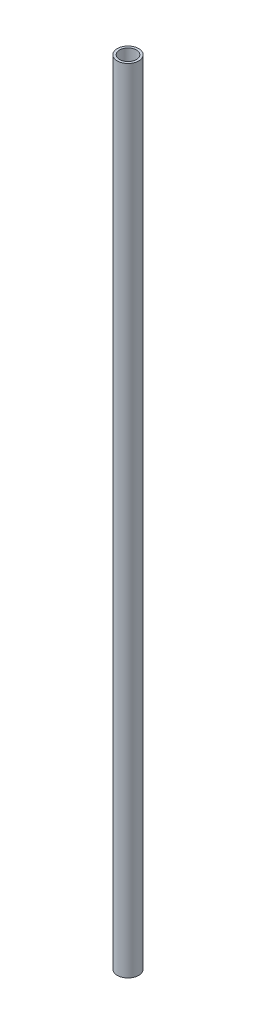
from build123d import *

# Parameters (mm, degrees)
SKETCH1_R           = 4.064
SKETCH1_R_2         = 3.175
BOSS_EXTRUDE1_DEPTH = 300


with BuildPart() as part:
    # Sketch1 → Boss-Extrude1 (new body)
    with BuildSketch(Plane(origin=(0, 0, 0), x_dir=(1, 0, 0), z_dir=(0, 1, 0))):
        Circle(SKETCH1_R)
        Circle(SKETCH1_R_2, mode=Mode.SUBTRACT)
    extrude(amount=BOSS_EXTRUDE1_DEPTH)


solid = part.part
